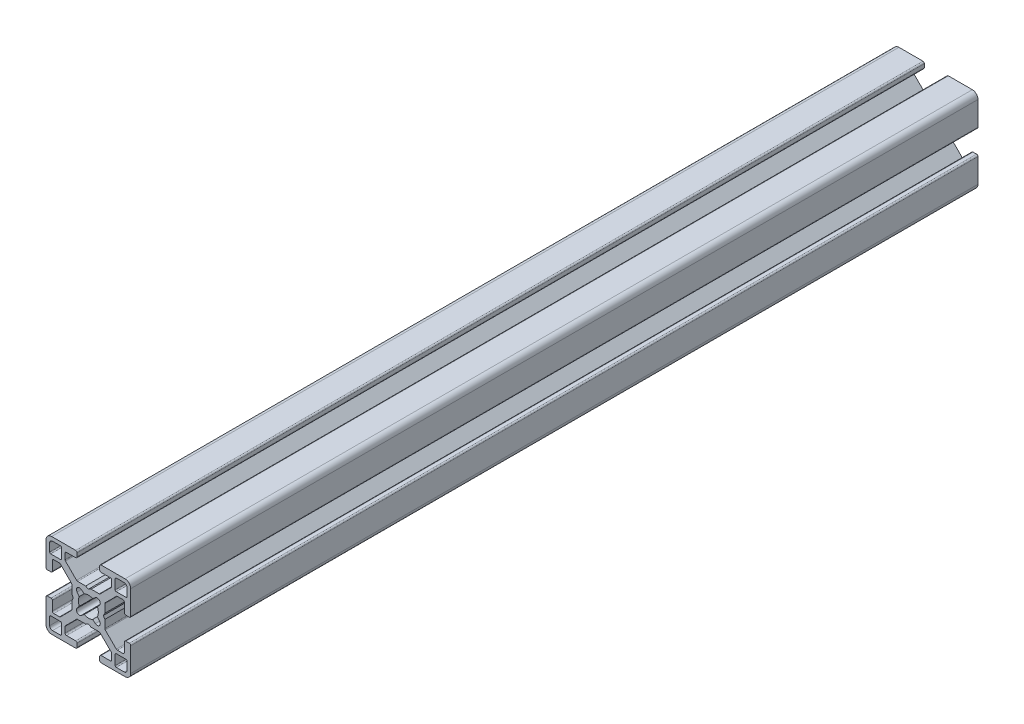
from build123d import *

# Parameters (mm, degrees)
EXTRUDE1_DEPTH = 300


with BuildPart() as part:
    # Sketch1 → Extrude1 (new body)
    with BuildSketch(Plane.XY):
        with BuildLine():
            Line((12.74247465, -4.5), (12.74247465, -7.732519321))
            ThreePointArc((12.74247465, -7.732519321), (12.602449697, -8.097296796), (12.242781236, -8.249967))
            Line((12.242781236, -8.249967), (10.260188032, -8.249967))
            ThreePointArc((10.260188032, -8.249967), (10.068847082, -8.211906919), (9.906636056, -8.103520976))
            Line((9.906636056, -8.103520976), (5.981117769, -4.178002689))
            ThreePointArc((5.981117769, -4.178002689), (5.872731827, -4.015791664), (5.834671745, -3.824450713))
            Line((5.834671745, -3.824450713), (5.834671745, -1.01249595))
            Line((5.834671745, -1.01249595), (5.324673785, -0.06249975))
            Line((5.324673785, -0.06249975), (5.834671745, 0.88749645))
            Line((5.834671745, 0.88749645), (5.834671745, 3.824450713))
            ThreePointArc((5.834671745, 3.824450713), (5.872731827, 4.015791664), (5.981117769, 4.178002689))
            Line((5.981117769, 4.178002689), (9.906636056, 8.103520976))
            ThreePointArc((9.906636056, 8.103520976), (10.068847082, 8.211906919), (10.260188032, 8.249967))
            Line((10.260188032, 8.249967), (12.242781236, 8.249967))
            ThreePointArc((12.242781236, 8.249967), (12.602449697, 8.097296796), (12.74247465, 7.732519321))
            Line((12.74247465, 7.732519321), (12.74247465, 4.5))
            ThreePointArc((12.74247465, 4.5), (12.88892126, 4.146446609), (13.24247465, 4))
            Line((13.24247465, 4), (14.49994, 4))
            ThreePointArc((14.49994, 4), (14.853493391, 4.146446609), (14.99994, 4.5))
            Line((14.99994, 4.5), (14.99994, 12.999948))
            ThreePointArc((14.99994, 12.999948), (14.414155906, 14.414155906), (12.999948, 14.99994))
            Line((12.999948, 14.99994), (4.5, 14.99994))
            ThreePointArc((4.5, 14.99994), (4.146446609, 14.853493391), (4, 14.49994))
            Line((4, 14.49994), (4, 13.24247465))
            ThreePointArc((4, 13.24247465), (4.146446609, 12.88892126), (4.5, 12.74247465))
            Line((4.5, 12.74247465), (7.732519321, 12.74247465))
            ThreePointArc((7.732519321, 12.74247465), (8.097296796, 12.602449697), (8.249967, 12.242781236))
            Line((8.249967, 12.242781236), (8.249967, 10.260188032))
            ThreePointArc((8.249967, 10.260188032), (8.211906919, 10.068847082), (8.103520976, 9.906636056))
            Line((8.103520976, 9.906636056), (4.178002689, 5.981117769))
            ThreePointArc((4.178002689, 5.981117769), (4.015791664, 5.872731827), (3.824450713, 5.834671745))
            Line((3.824450713, 5.834671745), (0.9499962, 5.834671745))
            Line((0.9499962, 5.834671745), (0, 5.324673785))
            Line((0, 5.324673785), (-0.9499962, 5.834671745))
            Line((-0.9499962, 5.834671745), (-3.824450713, 5.834671745))
            ThreePointArc((-3.824450713, 5.834671745), (-4.015791664, 5.872731827), (-4.178002689, 5.981117769))
            Line((-4.178002689, 5.981117769), (-8.103520976, 9.906636056))
            ThreePointArc((-8.103520976, 9.906636056), (-8.211906919, 10.068847082), (-8.249967, 10.260188032))
            Line((-8.249967, 10.260188032), (-8.249967, 12.242781236))
            ThreePointArc((-8.249967, 12.242781236), (-8.097296796, 12.602449697), (-7.732519321, 12.74247465))
            Line((-7.732519321, 12.74247465), (-4.5, 12.74247465))
            ThreePointArc((-4.5, 12.74247465), (-4.146446609, 12.88892126), (-4, 13.24247465))
            Line((-4, 13.24247465), (-4, 14.49994))
            ThreePointArc((-4, 14.49994), (-4.146446609, 14.853493391), (-4.5, 14.99994))
            Line((-4.5, 14.99994), (-12.999948, 14.99994))
            ThreePointArc((-12.999948, 14.99994), (-14.414155906, 14.414155906), (-14.99994, 12.999948))
            Line((-14.99994, 12.999948), (-14.99994, 4.5))
            ThreePointArc((-14.99994, 4.5), (-14.853493391, 4.146446609), (-14.49994, 4))
            Line((-14.49994, 4), (-13.24247465, 4))
            ThreePointArc((-13.24247465, 4), (-12.88892126, 4.146446609), (-12.74247465, 4.5))
            Line((-12.74247465, 4.5), (-12.74247465, 7.732519321))
            ThreePointArc((-12.74247465, 7.732519321), (-12.602449697, 8.097296796), (-12.242781236, 8.249967))
            Line((-12.242781236, 8.249967), (-10.260188032, 8.249967))
            ThreePointArc((-10.260188032, 8.249967), (-10.068847082, 8.211906919), (-9.906636056, 8.103520976))
            Line((-9.906636056, 8.103520976), (-5.981117769, 4.178002689))
            ThreePointArc((-5.981117769, 4.178002689), (-5.872731827, 4.015791664), (-5.834671745, 3.824450713))
            Line((-5.834671745, 3.824450713), (-5.834671745, 0.88749645))
            Line((-5.834671745, 0.88749645), (-5.324673785, -0.06249975))
            Line((-5.324673785, -0.06249975), (-5.834671745, -1.01249595))
            Line((-5.834671745, -1.01249595), (-5.834671745, -3.824450713))
            ThreePointArc((-5.834671745, -3.824450713), (-5.872731827, -4.015791664), (-5.981117769, -4.178002689))
            Line((-5.981117769, -4.178002689), (-9.906636056, -8.103520976))
            ThreePointArc((-9.906636056, -8.103520976), (-10.068847082, -8.211906919), (-10.260188032, -8.249967))
            Line((-10.260188032, -8.249967), (-12.242781236, -8.249967))
            ThreePointArc((-12.242781236, -8.249967), (-12.602449697, -8.097296796), (-12.74247465, -7.732519321))
            Line((-12.74247465, -7.732519321), (-12.74247465, -4.5))
            ThreePointArc((-12.74247465, -4.5), (-12.88892126, -4.146446609), (-13.24247465, -4))
            Line((-13.24247465, -4), (-14.49994, -4))
            ThreePointArc((-14.49994, -4), (-14.853493391, -4.146446609), (-14.99994, -4.5))
            Line((-14.99994, -4.5), (-14.99994, -12.999948))
            ThreePointArc((-14.99994, -12.999948), (-14.414155906, -14.414155906), (-12.999948, -14.99994))
            Line((-12.999948, -14.99994), (-4.5, -14.99994))
            ThreePointArc((-4.5, -14.99994), (-4.146446609, -14.853493391), (-4, -14.49994))
            Line((-4, -14.49994), (-4, -13.24247465))
            ThreePointArc((-4, -13.24247465), (-4.146446609, -12.88892126), (-4.5, -12.74247465))
            Line((-4.5, -12.74247465), (-7.732519321, -12.74247465))
            ThreePointArc((-7.732519321, -12.74247465), (-8.097296796, -12.602449697), (-8.249967, -12.242781236))
            Line((-8.249967, -12.242781236), (-8.249967, -10.260188032))
            ThreePointArc((-8.249967, -10.260188032), (-8.211906919, -10.068847082), (-8.103520976, -9.906636056))
            Line((-8.103520976, -9.906636056), (-4.178002689, -5.981117769))
            ThreePointArc((-4.178002689, -5.981117769), (-4.015791664, -5.872731827), (-3.824450713, -5.834671745))
            Line((-3.824450713, -5.834671745), (-0.9499962, -5.834671745))
            Line((-0.9499962, -5.834671745), (0, -5.324673785))
            Line((0, -5.324673785), (0.9499962, -5.834671745))
            Line((0.9499962, -5.834671745), (3.824450713, -5.834671745))
            ThreePointArc((3.824450713, -5.834671745), (4.015791664, -5.872731827), (4.178002689, -5.981117769))
            Line((4.178002689, -5.981117769), (8.103520976, -9.906636056))
            ThreePointArc((8.103520976, -9.906636056), (8.211906919, -10.068847082), (8.249967, -10.260188032))
            Line((8.249967, -10.260188032), (8.249967, -12.242781236))
            ThreePointArc((8.249967, -12.242781236), (8.097296796, -12.602449697), (7.732519321, -12.74247465))
            Line((7.732519321, -12.74247465), (4.5, -12.74247465))
            ThreePointArc((4.5, -12.74247465), (4.146446609, -12.88892126), (4, -13.24247465))
            Line((4, -13.24247465), (4, -14.49994))
            ThreePointArc((4, -14.49994), (4.146446609, -14.853493391), (4.5, -14.99994))
            Line((4.5, -14.99994), (12.999948, -14.99994))
            ThreePointArc((12.999948, -14.99994), (14.414155906, -14.414155906), (14.99994, -12.999948))
            Line((14.99994, -12.999948), (14.99994, -4.5))
            ThreePointArc((14.99994, -4.5), (14.853493391, -4.146446609), (14.49994, -4))
            Line((14.49994, -4), (13.24247465, -4))
            ThreePointArc((13.24247465, -4), (12.88892126, -4.146446609), (12.74247465, -4.5))
        make_face()
        with BuildLine():
            Line((9.499962, -13.318946724), (9.499962, -9.87996048))
            ThreePointArc((9.499962, -9.87996048), (9.611260978, -9.611260978), (9.87996048, -9.499962))
            Line((9.87996048, -9.499962), (13.318946724, -9.499962))
            ThreePointArc((13.318946724, -9.499962), (13.58835333, -9.61155387), (13.6999452, -9.880960476))
            Line((13.6999452, -9.880960476), (13.6999452, -12.6999492))
            ThreePointArc((13.6999452, -12.6999492), (13.407053153, -13.407053153), (12.6999492, -13.6999452))
            Line((12.6999492, -13.6999452), (9.880960476, -13.6999452))
            ThreePointArc((9.880960476, -13.6999452), (9.61155387, -13.58835333), (9.499962, -13.318946724))
        make_face(mode=Mode.SUBTRACT)
        with BuildLine():
            Line((-13.318946724, -9.499962), (-9.87996048, -9.499962))
            ThreePointArc((-9.87996048, -9.499962), (-9.611260978, -9.611260978), (-9.499962, -9.87996048))
            Line((-9.499962, -9.87996048), (-9.499962, -13.318946724))
            ThreePointArc((-9.499962, -13.318946724), (-9.61155387, -13.58835333), (-9.880960476, -13.6999452))
            Line((-9.880960476, -13.6999452), (-12.6999492, -13.6999452))
            ThreePointArc((-12.6999492, -13.6999452), (-13.407053153, -13.407053153), (-13.6999452, -12.6999492))
            Line((-13.6999452, -12.6999492), (-13.6999452, -9.880960476))
            ThreePointArc((-13.6999452, -9.880960476), (-13.58835333, -9.61155387), (-13.318946724, -9.499962))
        make_face(mode=Mode.SUBTRACT)
        with BuildLine():
            Line((-1.494225248, -3.198138712), (-2.473341823, -3.979927146))
            ThreePointArc((-2.473341823, -3.979927146), (-3.900227701, -3.900227701), (-3.979927146, -2.473341823))
            Line((-3.979927146, -2.473341823), (-3.198138712, -1.494225248))
            ThreePointArc((-3.198138712, -1.494225248), (-3.52998588, 0), (-3.198138712, 1.494225248))
            Line((-3.198138712, 1.494225248), (-3.979927146, 2.473341823))
            ThreePointArc((-3.979927146, 2.473341823), (-3.900227701, 3.900227701), (-2.473341823, 3.979927146))
            Line((-2.473341823, 3.979927146), (-1.494225248, 3.198138712))
            ThreePointArc((-1.494225248, 3.198138712), (0, 3.52998588), (1.494225248, 3.198138712))
            Line((1.494225248, 3.198138712), (2.473341823, 3.979927146))
            ThreePointArc((2.473341823, 3.979927146), (3.900227701, 3.900227701), (3.979927146, 2.473341823))
            Line((3.979927146, 2.473341823), (3.198138712, 1.494225248))
            ThreePointArc((3.198138712, 1.494225248), (3.52998588, 0), (3.198138712, -1.494225248))
            Line((3.198138712, -1.494225248), (3.979927146, -2.473341823))
            ThreePointArc((3.979927146, -2.473341823), (3.900227701, -3.900227701), (2.473341823, -3.979927146))
            Line((2.473341823, -3.979927146), (1.494225248, -3.198138712))
            ThreePointArc((1.494225248, -3.198138712), (0, -3.52998588), (-1.494225248, -3.198138712))
        make_face(mode=Mode.SUBTRACT)
        with BuildLine():
            Line((-9.499962, 13.318946724), (-9.499962, 9.87996048))
            ThreePointArc((-9.499962, 9.87996048), (-9.611260978, 9.611260978), (-9.87996048, 9.499962))
            Line((-9.87996048, 9.499962), (-13.318946724, 9.499962))
            ThreePointArc((-13.318946724, 9.499962), (-13.58835333, 9.61155387), (-13.6999452, 9.880960476))
            Line((-13.6999452, 9.880960476), (-13.6999452, 12.6999492))
            ThreePointArc((-13.6999452, 12.6999492), (-13.407053153, 13.407053153), (-12.6999492, 13.6999452))
            Line((-12.6999492, 13.6999452), (-9.880960476, 13.6999452))
            ThreePointArc((-9.880960476, 13.6999452), (-9.61155387, 13.58835333), (-9.499962, 13.318946724))
        make_face(mode=Mode.SUBTRACT)
        with BuildLine():
            Line((9.880960476, 13.6999452), (12.6999492, 13.6999452))
            ThreePointArc((12.6999492, 13.6999452), (13.407053153, 13.407053153), (13.6999452, 12.6999492))
            Line((13.6999452, 12.6999492), (13.6999452, 9.880960476))
            ThreePointArc((13.6999452, 9.880960476), (13.58835333, 9.61155387), (13.318946724, 9.499962))
            Line((13.318946724, 9.499962), (9.87996048, 9.499962))
            ThreePointArc((9.87996048, 9.499962), (9.611260978, 9.611260978), (9.499962, 9.87996048))
            Line((9.499962, 9.87996048), (9.499962, 13.318946724))
            ThreePointArc((9.499962, 13.318946724), (9.61155387, 13.58835333), (9.880960476, 13.6999452))
        make_face(mode=Mode.SUBTRACT)
    extrude(amount=-EXTRUDE1_DEPTH)


solid = part.part
